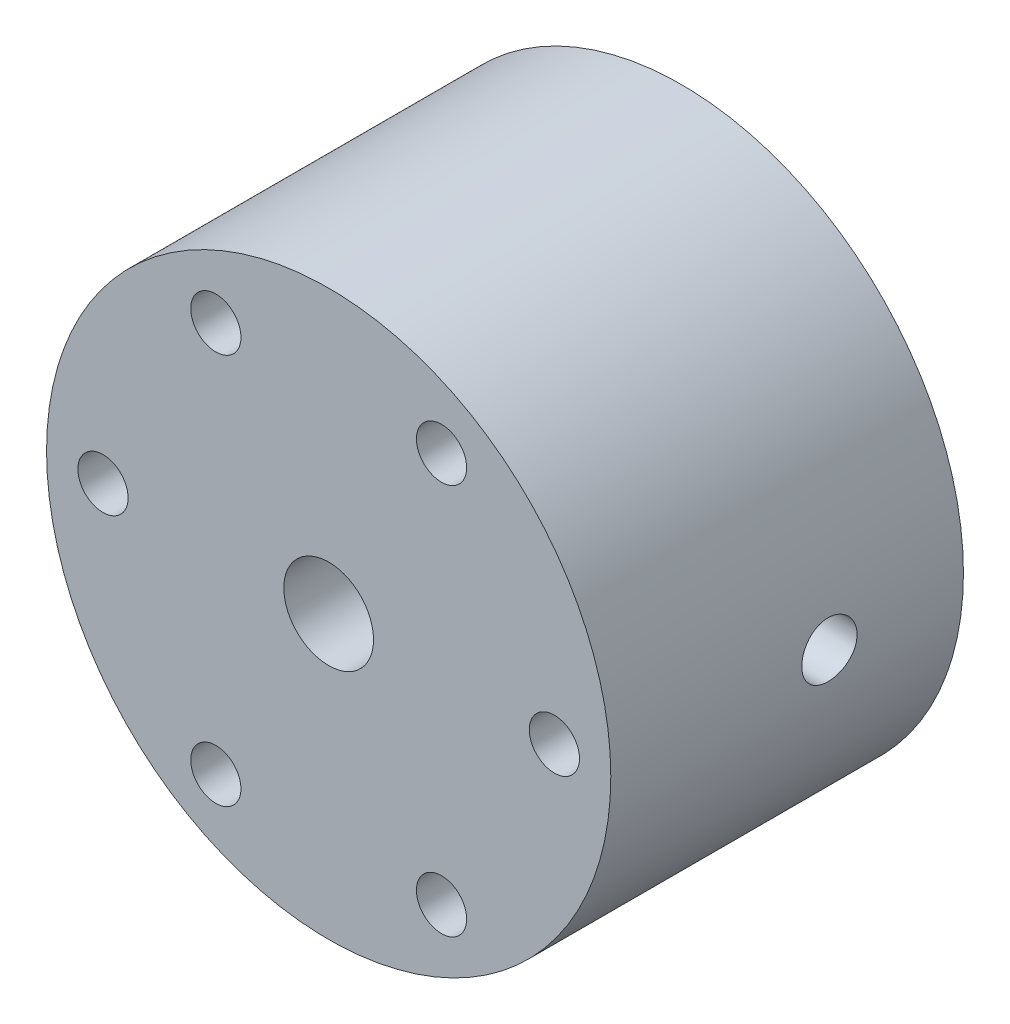
from build123d import *

# Parameters (mm, degrees)
SKETCH1_R                  = 12.7
BOSS_EXTRUDE1_DEPTH        = 15.875
SHELL1_T                   = -6.35
SKETCH4_R                  = 1.2446
CUT_EXTRUDE1_DEPTH         = 24.970724332
CUT_EXTRUDE1_DEPTH_BACK    = 24.970724332
SKETCH7_R                  = 7.6962
SKETCH7_R_2                = 6.35
CUT_EXTRUDE2_DEPTH         = 2.3622
TAP_DRILL_FOR_10_32_TAP1_D = 4.0386
CIRPATTERN1_COUNT          = 6


with BuildPart() as part:
    # Sketch1 → Boss-Extrude1 (new body)
    with BuildSketch(Plane.XY):
        Circle(SKETCH1_R)
    extrude(amount=-BOSS_EXTRUDE1_DEPTH)

    # Shell1
    shell1_openings = [part.faces().sort_by_distance(p)[0] for p in [
        (0, 0, -15.875),
    ]]
    offset(amount=SHELL1_T, openings=shell1_openings, kind=Kind.INTERSECTION)

    # Sketch4 → Cut-Extrude1 (cut, two sides)
    with BuildSketch(Plane(origin=(0, 0, 0), x_dir=(0, 0, -1), z_dir=(1, 0, 0))) as cut_extrude1_sk:
        with Locations((9.8425, 0)):
            Circle(SKETCH4_R)
    extrude(amount=CUT_EXTRUDE1_DEPTH, mode=Mode.SUBTRACT)
    extrude(cut_extrude1_sk.sketch, amount=-CUT_EXTRUDE1_DEPTH_BACK, mode=Mode.SUBTRACT)

    # Sketch7 → Cut-Extrude2 (cut)
    with BuildSketch(Plane(origin=(0, 0, -14.605), x_dir=(-1, 0, 0), z_dir=(0, 0, -1))):
        Circle(SKETCH7_R)
        with Locations(Location((0, 0, 0), (0, 0, 180))):
            Circle(SKETCH7_R_2, mode=Mode.SUBTRACT)
    extrude(amount=-CUT_EXTRUDE2_DEPTH, mode=Mode.SUBTRACT)

    # Tap Drill for #10-32 Tap1 (through all)
    with Locations(Plane.XY):
        with Locations((0, 0)):
            Hole(TAP_DRILL_FOR_10_32_TAP1_D / 2)

    # Sketch15 → Tap Drill for #4-40 Tap1 (revolve, cut)
    with BuildSketch(Plane(origin=(-10.16, 0, 0), x_dir=(0, -1, 0), z_dir=(1, 0, 0))):
        Polygon((0, 0), (0, 5.759152758), (1.1303, 5.08), (1.1303, 0), align=None)
    tap_drill_for_4_40_tap1 = revolve(axis=Axis((-10.16, 0, 6.35), (0, 0, -1)), mode=Mode.SUBTRACT)

    # CirPattern1: Tap Drill for #4-40 Tap1 ×6 about axis
    cirpattern1_axis = Axis((0, 0, 0), (0, 0, 1))
    for i in range(1, CIRPATTERN1_COUNT):
        add(tap_drill_for_4_40_tap1.rotate(cirpattern1_axis, i * 360 / CIRPATTERN1_COUNT), mode=Mode.SUBTRACT)


solid = part.part
